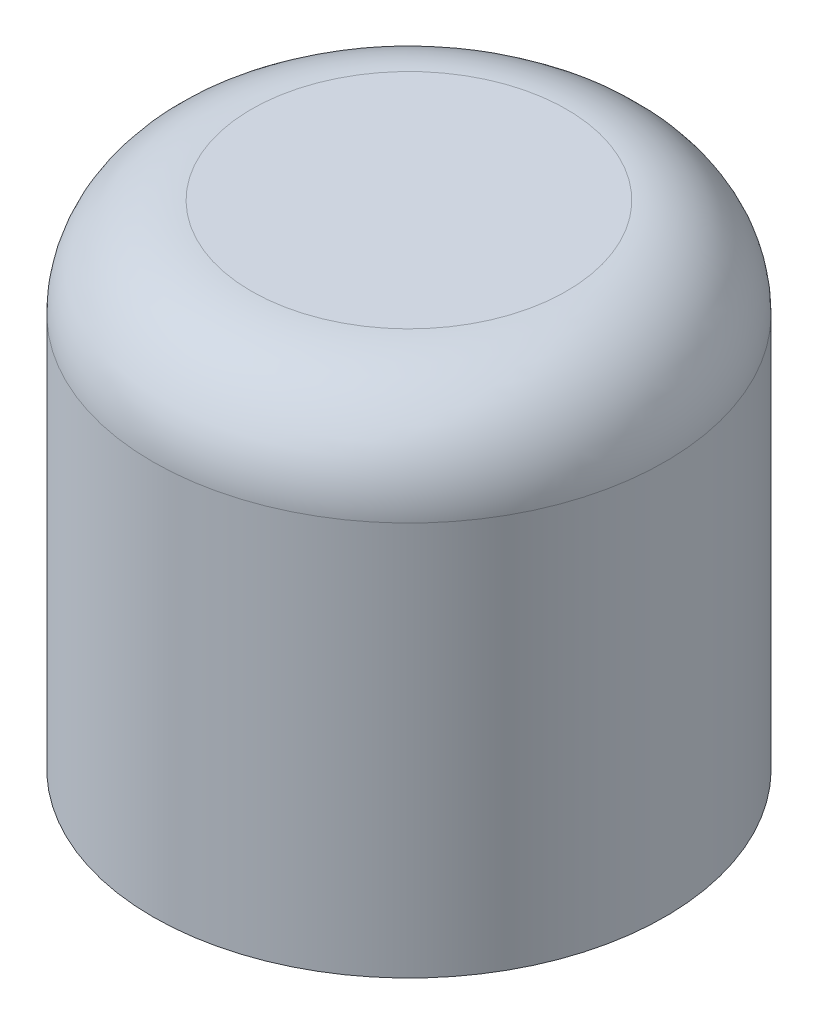
from build123d import *

# Parameters (mm, degrees)
SKETCH1_R           = 2.6
BOSS_EXTRUDE1_DEPTH = 5
FILLET1_R           = 1


with BuildPart() as part:
    # Sketch1 → Boss-Extrude1 (new body)
    with BuildSketch(Plane(origin=(0, 0, 0), x_dir=(1, 0, 0), z_dir=(0, 1, 0))):
        Circle(SKETCH1_R)
    extrude(amount=BOSS_EXTRUDE1_DEPTH)

    # Fillet1
    fillet1_edges = [part.edges().sort_by_distance(p)[0] for p in [
        (-2.6, 5, 0),
    ]]
    fillet(fillet1_edges, radius=FILLET1_R)


solid = part.part
